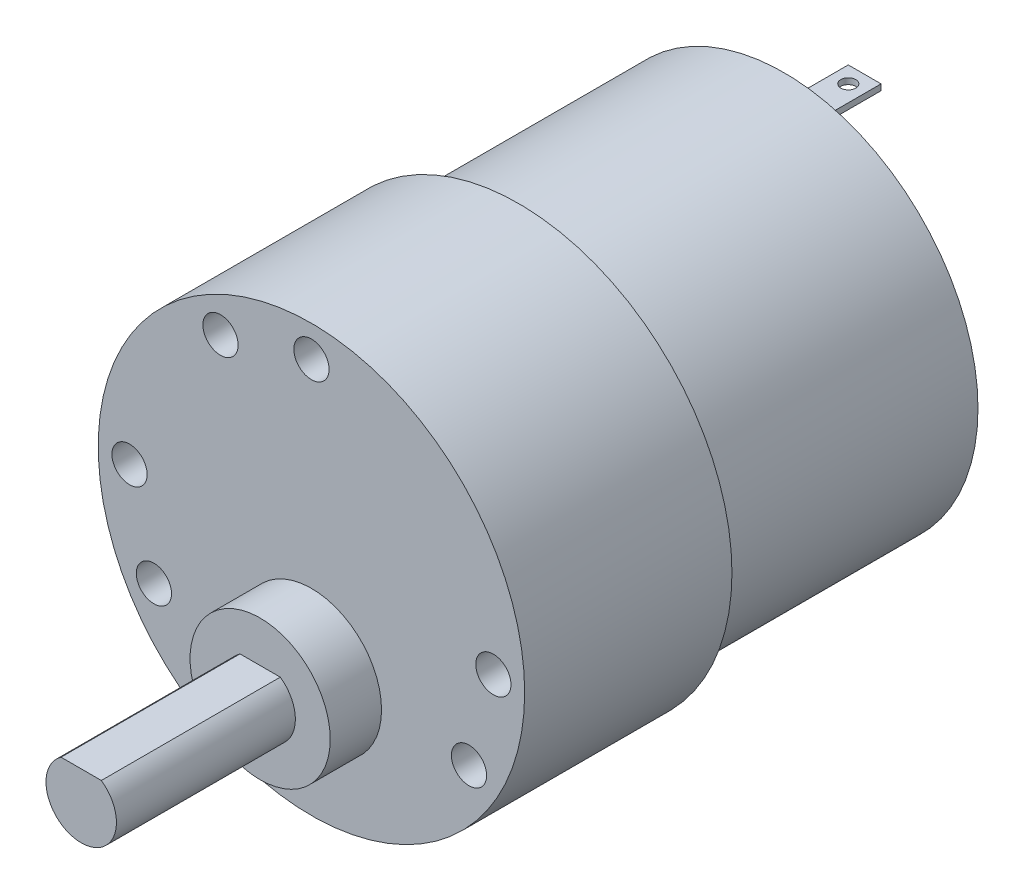
from build123d import *

# Parameters (mm, degrees)
SKETCH1_R           = 18.161
BOSS_EXTRUDE1_DEPTH = 17.653
SKETCH2_R           = 16.51
BOSS_EXTRUDE2_DEPTH = 22.606
SKETCH3_R           = 4.5085
BOSS_EXTRUDE3_DEPTH = 3.302
SKETCH4_R           = 2.413
BOSS_EXTRUDE4_DEPTH = 1.27
SKETCH5_R           = 5.969
BOSS_EXTRUDE5_DEPTH = 4.3688
BOSS_EXTRUDE6_DEPTH = 15.24
SKETCH8_W           = 5.588
SKETCH8_H           = 2.794
SKETCH8_R           = 0.635
BOSS_EXTRUDE7_DEPTH = 0.254
CIRPATTERN1_COUNT   = 2
CIRPATTERN2_COUNT   = 12


with BuildPart() as part:
    # Sketch1 → Boss-Extrude1 (new body)
    with BuildSketch(Plane.XY):
        Circle(SKETCH1_R)
    extrude(amount=BOSS_EXTRUDE1_DEPTH)

    # Sketch2 → Boss-Extrude2 (add)
    with BuildSketch(Plane(origin=(0, 0, 0), x_dir=(-1, 0, 0), z_dir=(0, 0, -1))):
        Circle(SKETCH2_R)
    extrude(amount=BOSS_EXTRUDE2_DEPTH)

    # Sketch3 → Boss-Extrude3 (add)
    with BuildSketch(Plane(origin=(0, 0, -22.606), x_dir=(-1, 0, 0), z_dir=(0, 0, -1))):
        Circle(SKETCH3_R)
    extrude(amount=BOSS_EXTRUDE3_DEPTH)

    # Sketch4 → Boss-Extrude4 (add)
    with BuildSketch(Plane(origin=(0, 0, -22.606), x_dir=(-1, 0, 0), z_dir=(0, 0, -1))):
        with Locations((0, -12.7)):
            Circle(SKETCH4_R)
        with Locations((0, 12.7)):
            Circle(SKETCH4_R)
    extrude(amount=BOSS_EXTRUDE4_DEPTH)

    # Sketch5 → Boss-Extrude5 (add)
    with BuildSketch(Plane.XY.offset(17.653)):
        with Locations((0, -7.366)):
            Circle(SKETCH5_R)
    extrude(amount=BOSS_EXTRUDE5_DEPTH)

    # Sketch6 → Boss-Extrude6 (add)
    with BuildSketch(Plane.XY.offset(22.0218)):
        with BuildLine():
            Line((-1.715657017, -4.905), (1.715657017, -4.905))
            ThreePointArc((1.715657017, -4.905), (0, -10.366), (-1.715657017, -4.905))
        make_face()
    extrude(amount=BOSS_EXTRUDE6_DEPTH)

    # Sketch8 → Boss-Extrude7 (add, symmetric)
    with BuildSketch(Plane.ZX.offset(12.7)):
        with Locations((-26.67, 0)):
            Rectangle(SKETCH8_W, SKETCH8_H)
        with Locations((-28.067, 0)):
            Circle(SKETCH8_R, mode=Mode.SUBTRACT)
    boss_extrude7 = extrude(amount=BOSS_EXTRUDE7_DEPTH, both=True)

    # CirPattern1: Boss-Extrude7 ×2 about axis
    cirpattern1_axis = Axis((0, 0, -25.908), (0, 0, 1))
    for i in range(1, CIRPATTERN1_COUNT):
        add(boss_extrude7.rotate(cirpattern1_axis, i * 360 / CIRPATTERN1_COUNT))

    # Sketch12 → Ø3.0mm Dowel Hole1 (revolve, cut)
    with BuildSketch(Plane(origin=(0, 15.494, 17.653), x_dir=(0, -1, 0), z_dir=(1, 0, 0))):
        Polygon((0, 0), (0, 11.061290929), (1.5, 10.16), (1.5, 0), align=None)
    f_3_0mm_dowel_hole1 = revolve(axis=Axis((0, 15.494, 24.003), (0, 0, -1)), mode=Mode.SUBTRACT)

    # CirPattern2: Ø3.0mm Dowel Hole1 ×12 about axis, 5 skipped
    cirpattern2_axis = Axis((0, 0, 17.653), (0, 0, -1))
    add([f_3_0mm_dowel_hole1.rotate(cirpattern2_axis, i * 360 / CIRPATTERN2_COUNT) for i in range(1, CIRPATTERN2_COUNT) if i not in (1, 2, 5, 6, 10)], mode=Mode.SUBTRACT)


solid = part.part
